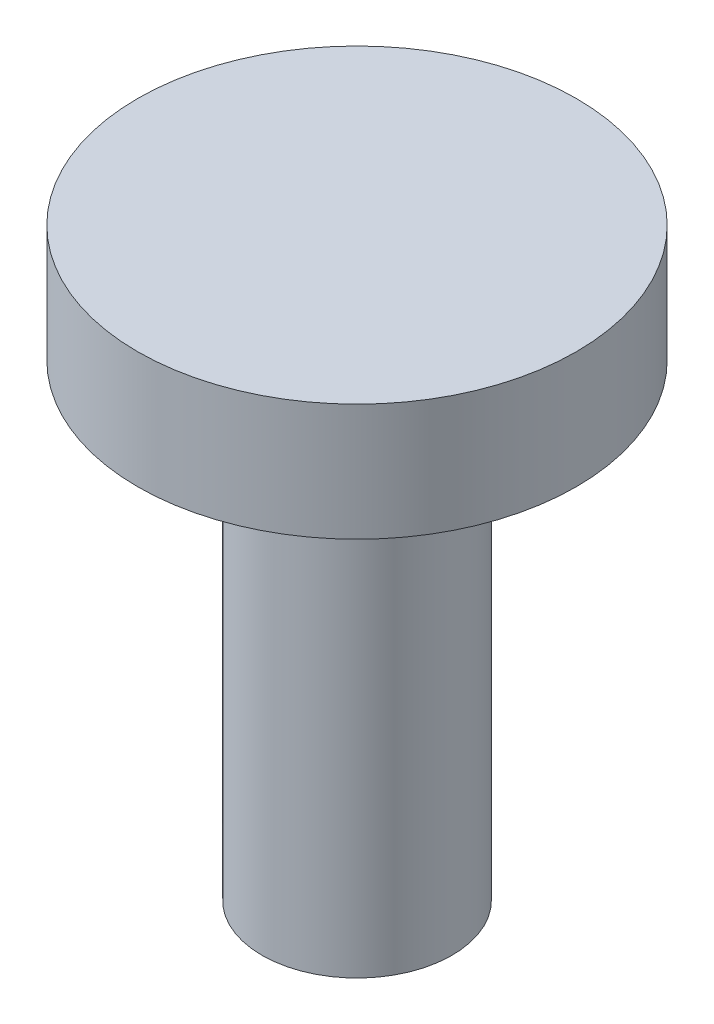
from build123d import *

# Parameters (mm, degrees)
SKETCH_1_R      = 3.25
EXTRUDE_1_DEPTH = 16
SKETCH_2_R      = 7.5
EXTRUDE_2_DEPTH = 4


with BuildPart() as part:
    # Эскиз1 → Бобышка-Вытянуть1 (new body)
    with BuildSketch(Plane(origin=(0, 0, 0), x_dir=(1, 0, 0), z_dir=(0, 1, 0))):
        Circle(SKETCH_1_R)
    extrude(amount=EXTRUDE_1_DEPTH)

    # Эскиз2 → Бобышка-Вытянуть2 (add)
    with BuildSketch(Plane(origin=(0, 16, 0), x_dir=(1, 0, 0), z_dir=(0, 1, 0))):
        Circle(SKETCH_2_R)
    extrude(amount=EXTRUDE_2_DEPTH)


solid = part.part
